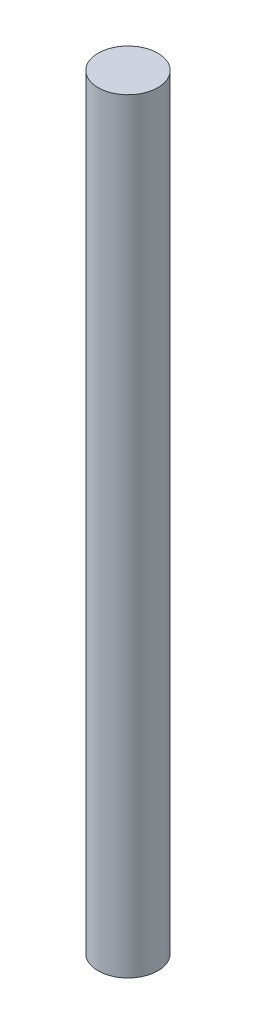
from build123d import *

# Parameters (mm, degrees)
SKETCH1_R           = 3.96875
BOSS_EXTRUDE1_DEPTH = 101.6


with BuildPart() as part:
    # Sketch1 → Boss-Extrude1 (new body)
    with BuildSketch(Plane(origin=(0, 0, 0), x_dir=(1, 0, 0), z_dir=(0, 1, 0))):
        Circle(SKETCH1_R)
    extrude(amount=BOSS_EXTRUDE1_DEPTH)


solid = part.part
